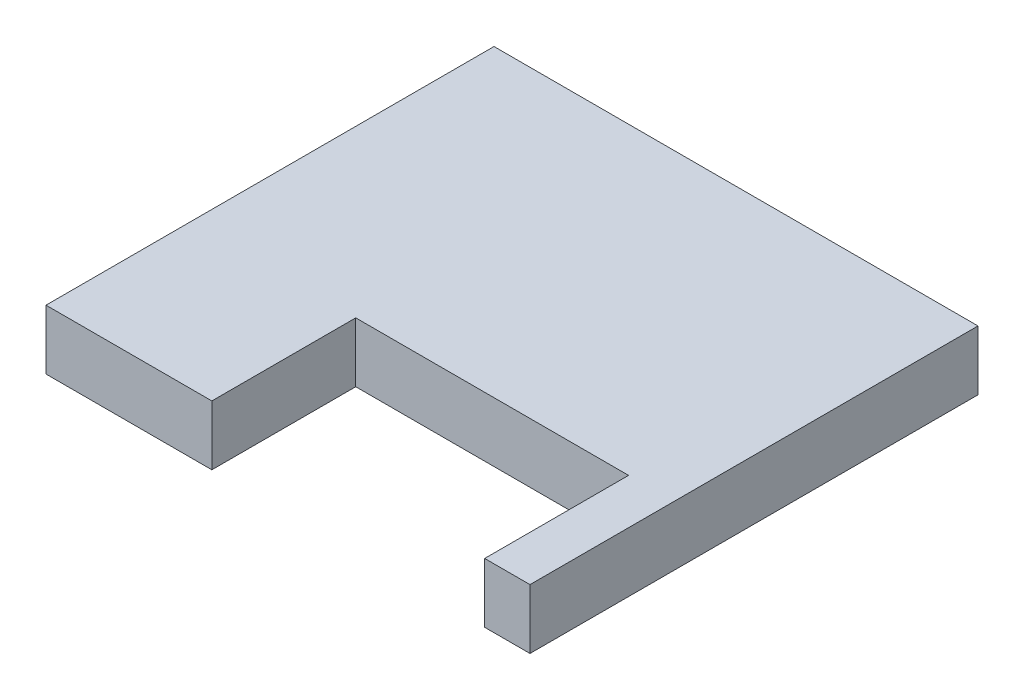
from build123d import *

# Parameters (mm, degrees)
BOSS_EXTRUDE1_DEPTH = 13.59916


with BuildPart() as part:
    # Sketch1 → Boss-Extrude1 (new body)
    with BuildSketch(Plane(origin=(0, 0, 0), x_dir=(1, 0, 0), z_dir=(0, 1, 0))):
        Polygon((110.307151448, 0), (110.307151448, 102.108), (0, 102.108), (0, 0), (37.800765592, 0), (37.800765592, 32.794), (99.980765724, 32.794), (99.980765724, 0), align=None)
    extrude(amount=BOSS_EXTRUDE1_DEPTH)


solid = part.part
